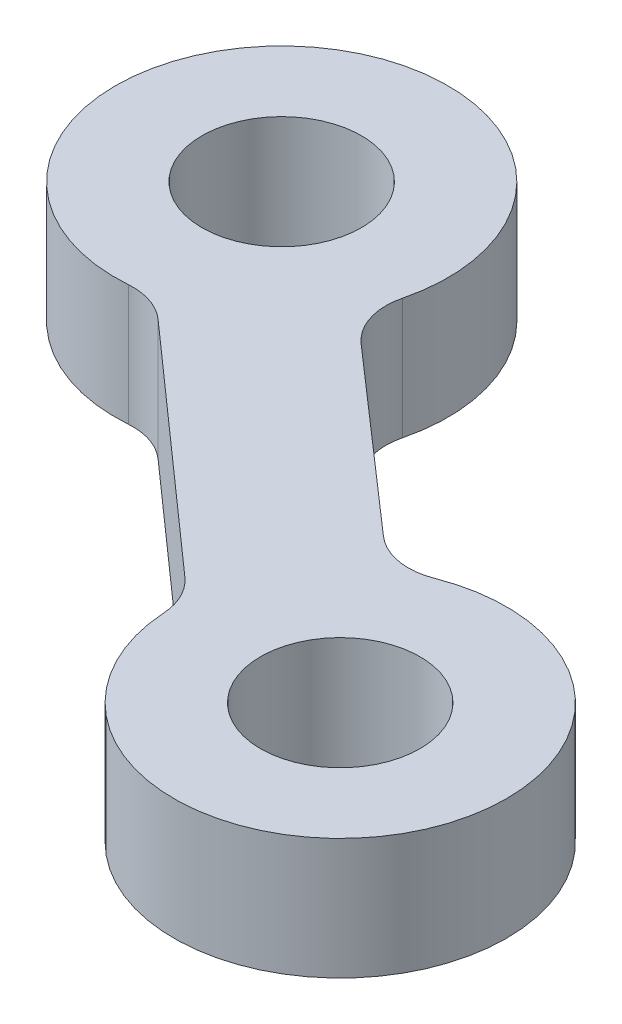
from build123d import *

# Parameters (mm, degrees)
SKETCH1_R           = 2.6375
BOSS_EXTRUDE1_DEPTH = 4


with BuildPart() as part:
    # Sketch1 → Boss-Extrude1 (new body)
    with BuildSketch(Plane.XZ):
        with BuildLine():
            Line((91.828846411, -34.604196587), (83.987808778, -41.556583288))
            ThreePointArc((83.987808778, -41.556583288), (83.299503374, -41.95543418), (82.510169812, -42.054423534))
            ThreePointArc((82.510169812, -42.054423534), (78.551510946, -51.744694217), (87.430169632, -46.200170264))
            ThreePointArc((87.430169632, -46.200170264), (87.461256355, -45.116261185), (88.053439291, -44.207886459))
            Line((88.053439291, -44.207886459), (93.937481824, -39.062233577))
            ThreePointArc((93.937481824, -39.062233577), (94.910198817, -38.597536781), (95.982821704, -38.705247518))
            ThreePointArc((95.982821704, -38.705247518), (102.625664422, -30.628415987), (92.497951624, -33.234562654))
            ThreePointArc((92.497951624, -33.234562654), (92.299001629, -33.985625361), (91.828846411, -34.604196587))
        make_face()
        with Locations((82.095552315, -47.538773298)):
            Circle(SKETCH1_R, mode=Mode.SUBTRACT)
        with Locations((97.986880619, -33.583358427)):
            Circle(SKETCH1_R, mode=Mode.SUBTRACT)
    extrude(amount=-BOSS_EXTRUDE1_DEPTH)


solid = part.part
